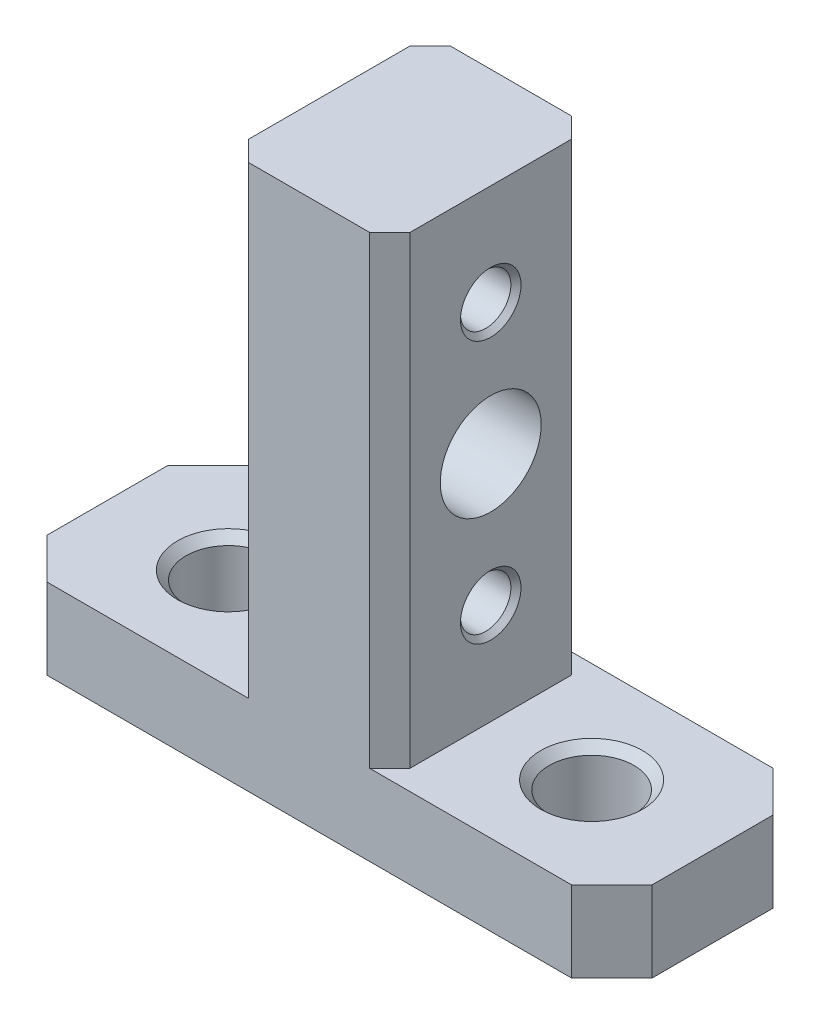
from build123d import *

# Parameters (mm, degrees)
EXTRUDE_1_DEPTH              = 10
CHAMFER_1_SIZE               = 2
CHAMFER_2_SIZE               = 1
CUT_EXTRUDE_2_REACH          = 21
SKETCH_3_R                   = 2.5
HOLE_WIZARD_M3_1_D           = 2.5
HOLE_WIZARD_M3_1_DEPTH       = 8
HOLE_WIZARD_M3_1_CSINK_D     = 3
HOLE_WIZARD_M3_1_CSINK_ANGLE = 90
HOLE_WIZARD_M5_1_D           = 4.2
HOLE_WIZARD_M5_1_DEPTH       = 4
HOLE_WIZARD_M5_1_CSINK_D     = 5.05
HOLE_WIZARD_M5_1_CSINK_ANGLE = 90


with BuildPart() as part:
    # 草图1 → 凸台-拉伸1 (new body)
    with BuildSketch(Plane.XY):
        Polygon((-41.573313116, -4.039574182), (-41.573313116, -8.039574182), (-11.573313116, -8.039574182), (-11.573313116, -4.039574182), (-22.573313116, -4.039574182), (-22.573313116, 18.960425818), (-30.573313116, 18.960425818), (-30.573313116, -4.039574182), align=None)
    extrude(amount=EXTRUDE_1_DEPTH)

    # 倒角1
    chamfer_1_edges = [part.edges().sort_by_distance(p)[0] for p in [
        (-11.573313116, -6.039574182, 0),
        (-41.573313116, -6.039574182, 0),
        (-11.573313116, -6.039574182, 10),
        (-41.573313116, -6.039574182, 10),
    ]]
    chamfer(chamfer_1_edges, length=CHAMFER_1_SIZE)

    # 倒角2
    chamfer_2_edges = [part.edges().sort_by_distance(p)[0] for p in [
        (-22.573313116, 7.460425818, 10),
        (-30.573313116, 7.460425818, 10),
        (-30.573313116, 7.460425818, 0),
        (-22.573313116, 7.460425818, 0),
    ]]
    chamfer(chamfer_2_edges, length=CHAMFER_2_SIZE)

    # 草图3 → 切除-拉伸2 (cut, up to next)
    with BuildSketch(Plane(origin=(-22.573313116, 0, 0), x_dir=(0, 0, -1), z_dir=(1, 0, 0)), mode=Mode.PRIVATE) as cut_extrude_2_sk1:
        with Locations((-5, 7.460425818)):
            Circle(SKETCH_3_R)
    cut_extrude_2_tool1 = extrude(cut_extrude_2_sk1.sketch, amount=-CUT_EXTRUDE_2_REACH, mode=Mode.PRIVATE) & part.part
    add(cut_extrude_2_tool1.solids().sort_by_distance((-22.573313, 7.460426, 5))[0], mode=Mode.SUBTRACT)

    # M3 螺纹孔1
    with Locations(Plane(origin=(-22.573313116, 13.960425818, 5), x_dir=(0, 0, 1), z_dir=(1, 0, 0))):
        with Locations((0, 0), (0, 13)):
            CounterSinkHole(HOLE_WIZARD_M3_1_D / 2, HOLE_WIZARD_M3_1_CSINK_D / 2, depth=HOLE_WIZARD_M3_1_DEPTH, counter_sink_angle=HOLE_WIZARD_M3_1_CSINK_ANGLE)

    # M5 螺纹孔1
    with Locations(Plane(origin=(-35.573313116, -4.039574182, 5), x_dir=(0, 0, 1), z_dir=(0, 1, 0))):
        with Locations((0, 0), (0, 18)):
            CounterSinkHole(HOLE_WIZARD_M5_1_D / 2, HOLE_WIZARD_M5_1_CSINK_D / 2, depth=HOLE_WIZARD_M5_1_DEPTH, counter_sink_angle=HOLE_WIZARD_M5_1_CSINK_ANGLE)


solid = part.part
